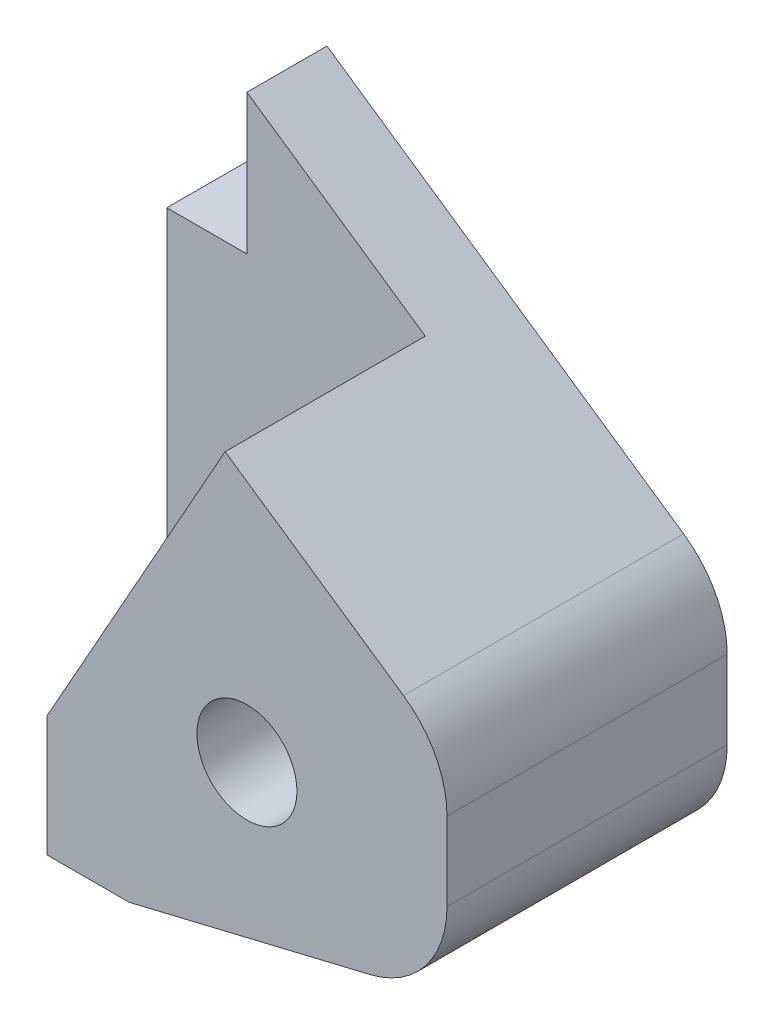
from build123d import *

# Parameters (mm, degrees)
SKETCH_1_R      = 2.5
EXTRUDE_1_DEPTH = 4
FILLET_1_R      = 5
SKETCH_2_R      = 2.5
EXTRUDE_2_DEPTH = 10


with BuildPart() as part:
    # ｽｹｯﾁ1 → ﾎﾞｽ - 押し出し1 (new body)
    with BuildSketch(Plane.XY):
        Polygon((0, 15), (0, 0), (4, 0), (4, -6), (8.110763801, -6), (24, -2.18322685), (24, 8.312378031), (4, 22), (4, 15), align=None)
        with Locations((14, 3)):
            Circle(SKETCH_1_R, mode=Mode.SUBTRACT)
    extrude(amount=EXTRUDE_1_DEPTH)

    # ﾌｨﾚｯﾄ1
    fillet_1_edges = [part.edges().sort_by_distance(p)[0] for p in [
        (24, -2.18322685, 2),
        (24, 8.312378031, 2),
    ]]
    fillet(fillet_1_edges, radius=FILLET_1_R)

    # ｽｹｯﾁ2 → ﾎﾞｽ - 押し出し2 (add)
    with BuildSketch(Plane.XY.offset(4)):
        with BuildLine():
            Line((4, 0), (4, -6))
            Line((4, -6), (8.110763801, -6))
            Line((8.110763801, -6), (20.167835798, -3.103755769))
            ThreePointArc((20.167835798, -3.103755769), (22.926778514, -1.337276232), (24, 1.757947589))
            Line((24, 1.757947589), (24, 5.675452184))
            ThreePointArc((24, 5.675452184), (23.422640317, 8.007887097), (21.823898951, 9.801660457))
            Line((21.823898951, 9.801660457), (12.911949475, 15.900830229))
            Line((12.911949475, 15.900830229), (4, 0))
        make_face()
        with Locations((14, 3)):
            Circle(SKETCH_2_R, mode=Mode.SUBTRACT)
    extrude(amount=EXTRUDE_2_DEPTH)


solid = part.part
